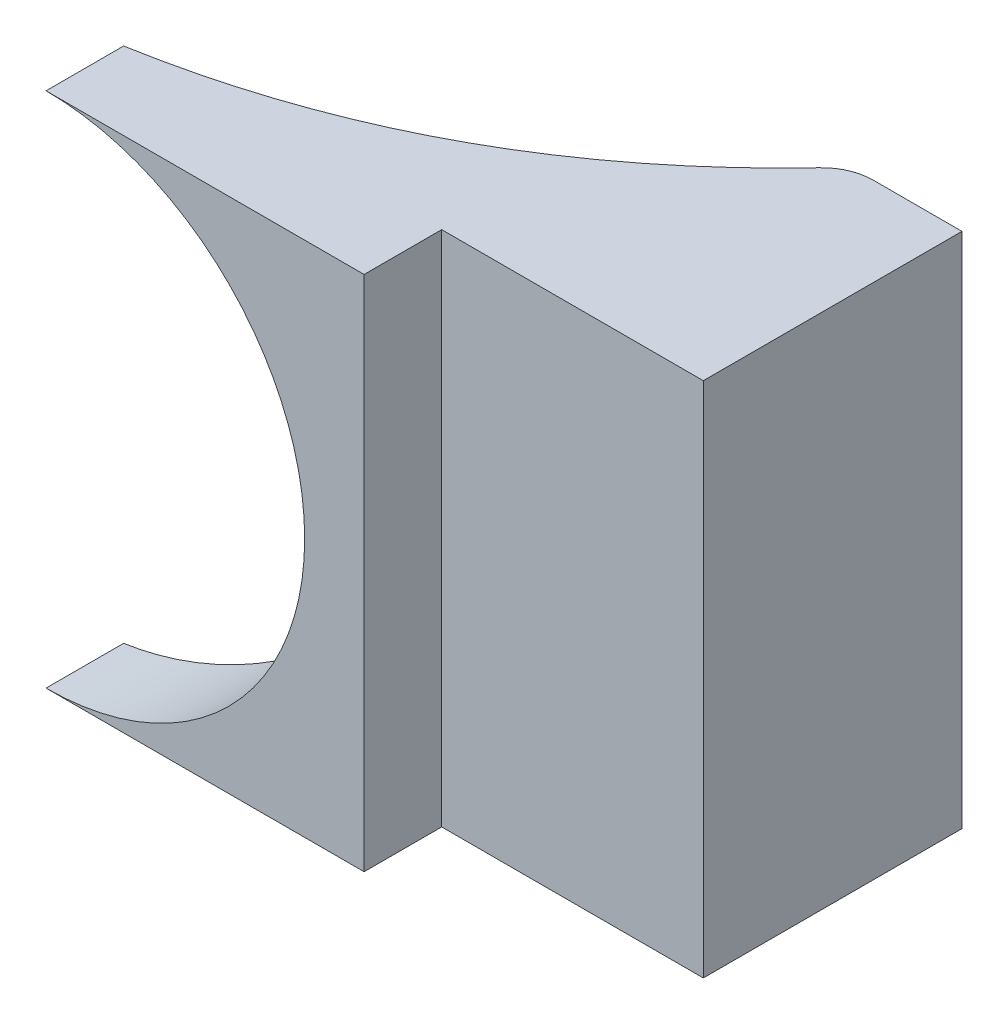
from build123d import *

# Parameters (mm, degrees)
BOSS_EXTRUDE1_DEPTH     = 50
CUT_EXTRUDE1_DEPTH      = 122
CUT_EXTRUDE1_DEPTH_BACK = 98
FILLET1_R               = 10
BOSS_EXTRUDE2_DEPTH     = 15


with BuildPart() as part:
    # Sketch1 → Boss-Extrude1 (new body)
    with BuildSketch(Plane.XY):
        with BuildLine():
            Line((112.060798049, 50), (0, 50))
            ThreePointArc((0, 50), (35.355339059, 35.355339059), (50, 0))
            ThreePointArc((50, 0), (35.355339059, -35.355339059), (0, -50))
            Line((0, -50), (112.060798049, -50))
            Line((112.060798049, -50), (112.060798049, 50))
        make_face()
    extrude(amount=BOSS_EXTRUDE1_DEPTH)

    # Sketch2 → Cut-Extrude1 (cut, two sides)
    with BuildSketch(Plane(origin=(0, 0, 0), x_dir=(1, 0, 0), z_dir=(0, 1, 0))) as cut_extrude1_sk:
        with BuildLine():
            Line((90.490413338, 0), (0, 0))
            Line((0, 0), (0, -50))
            add(Edge.make_bspline(
                [(0, -50), (54.321214116, -40.505522655), (90.490413338, 0)],
                knots=[0, 0, 0, 1, 1, 1], degree=2))
        make_face()
    extrude(amount=CUT_EXTRUDE1_DEPTH, mode=Mode.SUBTRACT)
    extrude(cut_extrude1_sk.sketch, amount=-CUT_EXTRUDE1_DEPTH_BACK, mode=Mode.SUBTRACT)

    # Fillet1
    fillet1_edges = [part.edges().sort_by_distance(p)[0] for p in [
        (90.490413338, -25, 0),
    ]]
    fillet(fillet1_edges, radius=FILLET1_R)

    # Sketch3 → Boss-Extrude2 (add)
    with BuildSketch(Plane.XY.offset(50)):
        with BuildLine():
            Line((0, 50), (61.486792526, 50))
            Line((61.486792526, 50), (61.486792526, -50))
            Line((61.486792526, -50), (0, -50))
            ThreePointArc((0, -50), (50, 0), (0, 50))
        make_face()
    extrude(amount=BOSS_EXTRUDE2_DEPTH)


solid = part.part
